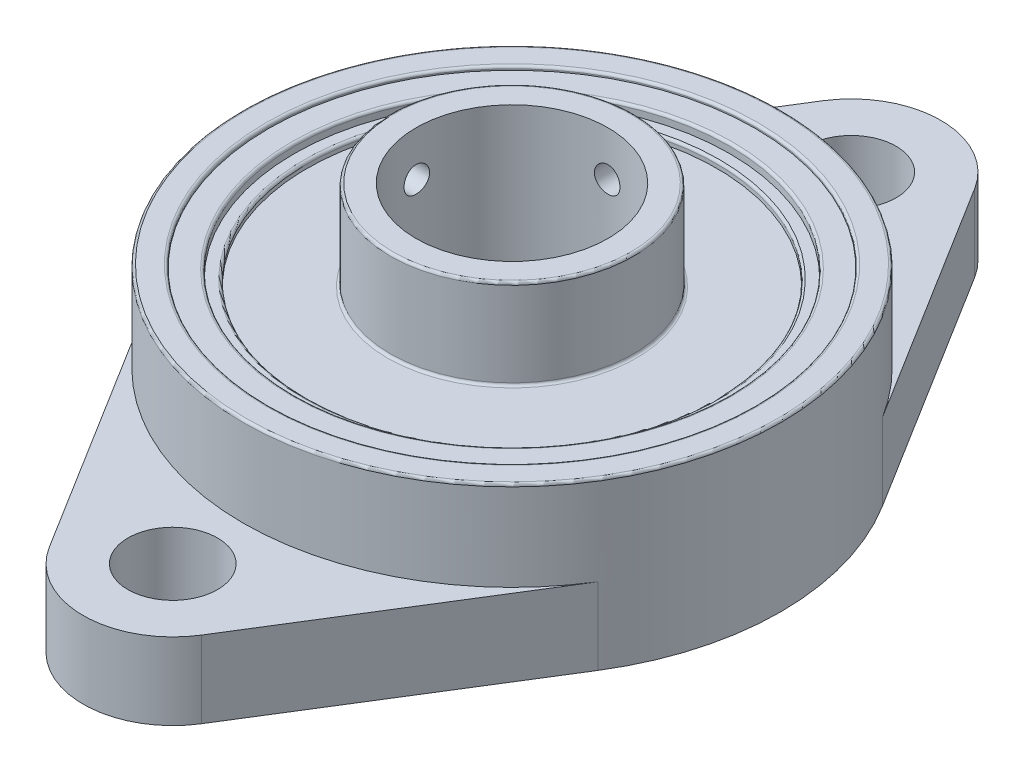
from build123d import *

# Parameters (mm, degrees)
SKETCH1_R             = 3.5
SKETCH1_R_2           = 19
EXTRUDE_A1_DEPTH      = 6
SKETCH1_3_R           = 19
EXTRUDE_A_DEPTH       = 13
SKETCH1_4_R           = 9.5
SKETCH1_4_R_2         = 7.5
EXTRUDE_A0_DEPTH      = 18.5
BEARING_START         = 2
SKETCH1_7_R           = 17
SKETCH1_7_R_2         = 16
BEARING_OUTER_D_DEPTH = 10
BOSS_EXTRUDE6_START   = 1.2
SKETCH1_8_R           = 19
SKETCH1_8_R_2         = 17
BOSS_EXTRUDE6_DEPTH   = 11.5
BOSS_EXTRUDE7_START   = 1.5
SKETCH1_9_R           = 16
SKETCH1_9_R_2         = 9.5
BOSS_EXTRUDE7_DEPTH   = 10
CUT_EXTRUDE1_REACH    = 45.652
SKETCH2_R             = 1
CUT_EXTRUDE2_REACH    = 45.652
SKETCH3_R             = 1
FILLET1_R             = 0.2
FILLET2_R             = 0.2


with BuildPart() as part:
    # Sketch1 → Extrude A1 (new body)
    with BuildSketch(Plane(origin=(0, 0, 0), x_dir=(1, 0, 0), z_dir=(0, 1, 0))):
        with BuildLine():
            Line((5.943396226, -30.198113208), (17.830188679, -11.094339623))
            ThreePointArc((17.830188679, -11.094339623), (21, 0), (17.830188679, 11.094339623))
            Line((17.830188679, 11.094339623), (5.943396226, 30.198113208))
            ThreePointArc((5.943396226, 30.198113208), (0, 33.5), (-5.943396226, 30.198113208))
            Line((-5.943396226, 30.198113208), (-17.830188679, 11.094339623))
            ThreePointArc((-17.830188679, 11.094339623), (-21, 0), (-17.830188679, -11.094339623))
            Line((-17.830188679, -11.094339623), (-5.943396226, -30.198113208))
            ThreePointArc((-5.943396226, -30.198113208), (0, -33.5), (5.943396226, -30.198113208))
        make_face()
        with Locations((0, -26.5)):
            Circle(SKETCH1_R, mode=Mode.SUBTRACT)
        Circle(SKETCH1_R_2, mode=Mode.SUBTRACT)
        with Locations((0, 26.5)):
            Circle(SKETCH1_R, mode=Mode.SUBTRACT)
    extrude(amount=EXTRUDE_A1_DEPTH)

    # Sketch1_3 → Extrude A (add)
    with BuildSketch(Plane(origin=(0, 0, 0), x_dir=(1, 0, 0), z_dir=(0, 1, 0))):
        with BuildLine():
            ThreePointArc((-17.830188679, -11.094339623), (0, -21), (17.830188679, -11.094339623))
            ThreePointArc((17.830188679, -11.094339623), (20.1920029, -5.769143686), (21, 0))
            ThreePointArc((21, 0), (20.1920029, 5.769143686), (17.830188679, 11.094339623))
            ThreePointArc((17.830188679, 11.094339623), (0, 21), (-17.830188679, 11.094339623))
            ThreePointArc((-17.830188679, 11.094339623), (-21, 0), (-17.830188679, -11.094339623))
        make_face()
        Circle(SKETCH1_3_R, mode=Mode.SUBTRACT)
    extrude(amount=EXTRUDE_A_DEPTH)



with BuildPart() as body_2:
    # Sketch1_4 → Extrude A0 (new body)
    with BuildSketch(Plane(origin=(0, 0, 0), x_dir=(1, 0, 0), z_dir=(0, 1, 0))):
        Circle(SKETCH1_4_R)
        Circle(SKETCH1_4_R_2, mode=Mode.SUBTRACT)
    extrude(amount=EXTRUDE_A0_DEPTH)


with BuildPart() as body_3:
    # Sketch1_7 → Bearing outer d (new body)
    with BuildSketch(Plane(origin=(0, 0, 0), x_dir=(1, 0, 0), z_dir=(0, 1, 0)).offset(BEARING_START)):
        Circle(SKETCH1_7_R)
        Circle(SKETCH1_7_R_2, mode=Mode.SUBTRACT)
    extrude(amount=BEARING_OUTER_D_DEPTH)


with BuildPart() as part_1:
    add(part.part)

    add(body_3.part)  # Boss-Extrude6 merges body 3
    # Sketch1_8 → Boss-Extrude6 (add)
    with BuildSketch(Plane(origin=(0, 0, 0), x_dir=(1, 0, 0), z_dir=(0, 1, 0)).offset(BOSS_EXTRUDE6_START)):
        Circle(SKETCH1_8_R)
        Circle(SKETCH1_8_R_2, mode=Mode.SUBTRACT)
    extrude(amount=BOSS_EXTRUDE6_DEPTH)


    add(body_2.part)  # Boss-Extrude7 merges body 2
    # Sketch1_9 → Boss-Extrude7 (add)
    with BuildSketch(Plane(origin=(0, 0, 0), x_dir=(1, 0, 0), z_dir=(0, 1, 0)).offset(BOSS_EXTRUDE7_START)):
        Circle(SKETCH1_9_R)
        Circle(SKETCH1_9_R_2, mode=Mode.SUBTRACT)
    extrude(amount=BOSS_EXTRUDE7_DEPTH)

    # Sketch2 → Cut-Extrude1 (cut, up to next)
    with BuildSketch(Plane(origin=(0, 0, 0), x_dir=(0, 0, -1), z_dir=(1, 0, 0)), mode=Mode.PRIVATE) as cut_extrude1_sk1:
        with Locations((0, 15)):
            Circle(SKETCH2_R)
    cut_extrude1_tool1 = extrude(cut_extrude1_sk1.sketch, amount=-CUT_EXTRUDE1_REACH, mode=Mode.PRIVATE) & part_1.part
    add(cut_extrude1_tool1.solids().sort_by_distance((0, 15, 0))[0], mode=Mode.SUBTRACT)

    # Sketch3 → Cut-Extrude2 (cut, up to next)
    with BuildSketch(Plane.XY, mode=Mode.PRIVATE) as cut_extrude2_sk1:
        with Locations((0, 15)):
            Circle(SKETCH3_R)
    cut_extrude2_tool1 = extrude(cut_extrude2_sk1.sketch, amount=-CUT_EXTRUDE2_REACH, mode=Mode.PRIVATE) & part_1.part
    add(cut_extrude2_tool1.solids().sort_by_distance((0, 15, 0))[0], mode=Mode.SUBTRACT)

    # Fillet1
    fillet1_edges = [part_1.edges().sort_by_distance(p)[0] for p in [
        (-16, 12, 0),
    ]]
    fillet(fillet1_edges, radius=FILLET1_R)

    # Fillet2
    fillet2_edges = [part_1.edges().sort_by_distance(p)[0] for p in [
        (-9.5, 18.5, 0),
        (-9.5, 11.5, 0),
        (-17.830188679, 13, -11.094339623),
        (-19, 13, 0),
        (-17, 12.7, 0),
    ]]
    fillet(fillet2_edges, radius=FILLET2_R)


solid = part_1.part
